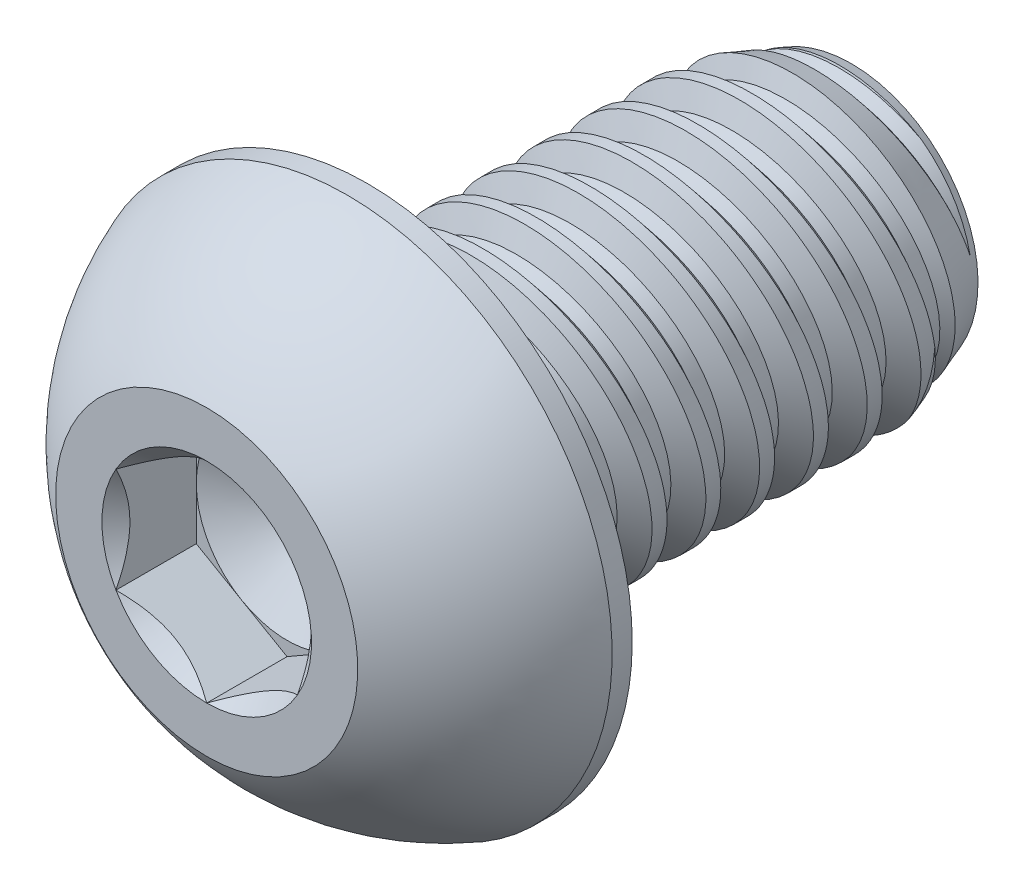
from build123d import *

# Parameters (mm, degrees)
SKETCH1_W          = 12.7
SKETCH1_H          = 3.9624
LPATTERN1_COUNT    = 9
LPATTERN1_PITCH    = 1.411111111
LPATTERN2_COUNT    = 2
LPATTERN2_PITCH    = 1.411111111
SKETCH4_R          = 6.9469
EXTRUDE1_DEPTH     = 4.2164
CUT_EXTRUDE1_DEPTH = 2.1082
SKETCH7_R          = 2.749630657
CUT_EXTRUDE4_DEPTH = 2.1082
CUT_EXTRUDE4_TAPER = 45
SKETCH8_R          = 2.38125
CUT_EXTRUDE5_DEPTH = 0.702733333
CUT_EXTRUDE5_TAPER = 60


with BuildPart() as part:
    # Sketch1 → Revolve1 (revolve)
    with BuildSketch(Plane(origin=(0, 0, 0), x_dir=(0, 0, -1), z_dir=(1, 0, 0))):
        with Locations((6.35, 1.9812)):
            Rectangle(SKETCH1_W, SKETCH1_H)
    revolve(axis=Axis((0, 0, 0), (0, 0, 1)))

    # Sketch2 → Cut-Revolve1 (revolve, cut)
    with BuildSketch(Plane(origin=(0, 0, 0), x_dir=(0, 0, -1), z_dir=(1, 0, 0))):
        Polygon((0.173657354, 3.993321894), (1.389258833, 4.209775148), (1.089011174, 3.380512014), (0.741696466, 3.318668226), align=None)
    cut_revolve1 = revolve(axis=Axis((0, -0.26919352, 0), (0, 0.175305223, -0.984514133)), mode=Mode.SUBTRACT)

    # Sketch3 → Cut-Revolve2 (revolve, cut)
    with BuildSketch(Plane(origin=(0, 0, 0), x_dir=(0, 0, -1), z_dir=(1, 0, 0))):
        Polygon((12.7, 3.318668226), (10.931361488, 3.9624), (12.7, 3.9624), align=None)
    revolve(axis=Axis((0, 0, -10.931361488), (0, 0, 1)), mode=Mode.SUBTRACT)

    # LPattern1: Cut-Revolve1 ×9
    with Locations(*[(0, 0, -i * LPATTERN1_PITCH) for i in range(1, LPATTERN1_COUNT)]):
        add(cut_revolve1, mode=Mode.SUBTRACT)

    # LPattern2: Cut-Revolve1 ×2
    with Locations(*[(0, 0, i * LPATTERN2_PITCH) for i in range(1, LPATTERN2_COUNT)]):
        add(cut_revolve1, mode=Mode.SUBTRACT)

    # Sketch4 → Extrude1 (add)
    with BuildSketch(Plane.XY):
        Circle(SKETCH4_R)
    extrude(amount=EXTRUDE1_DEPTH)

    # Sketch9 → Cut-Revolve3 (revolve, cut)
    with BuildSketch(Plane(origin=(0, 0, 0), x_dir=(0, 0, -1), z_dir=(1, 0, 0))):
        with BuildLine():
            Line((0, 6.9469), (-0.52705, 6.9469))
            ThreePointArc((-0.52705, 6.9469), (-2.617223162, 5.758127515), (-4.2164, 3.9624))
            Line((-4.2164, 3.9624), (-4.74345, 3.9624))
            Line((-4.74345, 3.9624), (-4.74345, 7.47395))
            Line((-4.74345, 7.47395), (0, 7.47395))
            Line((0, 7.47395), (0, 6.9469))
        make_face()
    revolve(axis=Axis((0, 0, 0), (0, 0, 1)), mode=Mode.SUBTRACT)

    # Sketch6 → Cut-Extrude1 (cut)
    with BuildSketch(Plane.XY.offset(4.2164)):
        Polygon((0, -2.749630657), (2.38125, -1.374815329), (2.38125, 1.374815329), (0, 2.749630657), (-2.38125, 1.374815329), (-2.38125, -1.374815329), align=None)
    extrude(amount=-CUT_EXTRUDE1_DEPTH, mode=Mode.SUBTRACT)

    # Sketch7 → Cut-Extrude4 (cut)
    with BuildSketch(Plane.XY.offset(4.2164)):
        Circle(SKETCH7_R)
    extrude(amount=-CUT_EXTRUDE4_DEPTH, taper=CUT_EXTRUDE4_TAPER, mode=Mode.SUBTRACT)

    # Sketch8 → Cut-Extrude5 (cut)
    with BuildSketch(Plane.XY.offset(2.1082)):
        Circle(SKETCH8_R)
    extrude(amount=-CUT_EXTRUDE5_DEPTH, taper=CUT_EXTRUDE5_TAPER, mode=Mode.SUBTRACT)


solid = part.part
